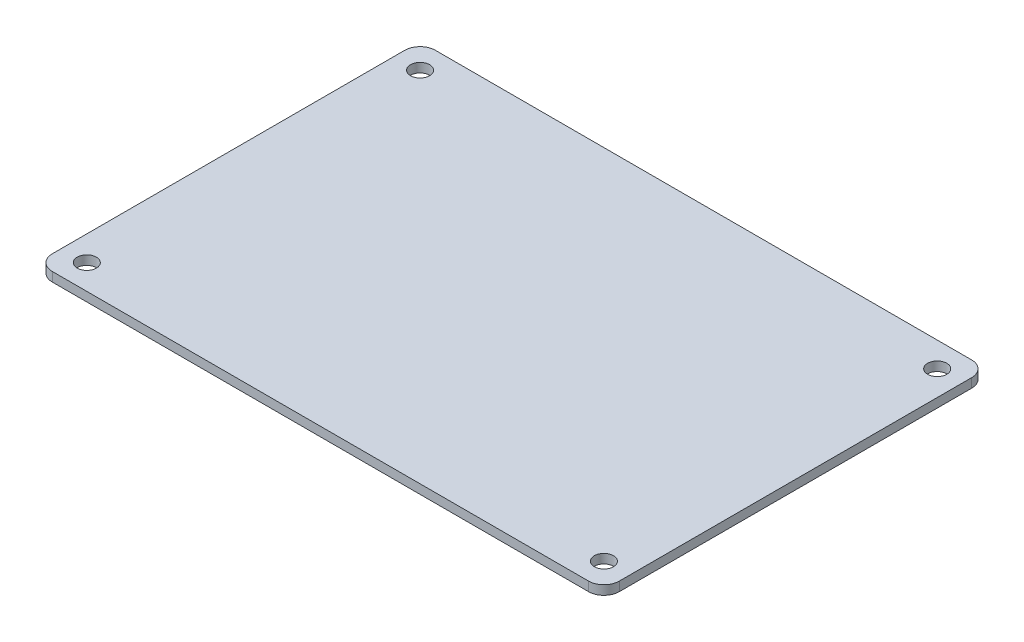
from build123d import *

# Parameters (mm, degrees)
BOSS_EXTRUDE1_DEPTH = 1.524
SKETCH2_R           = 1.5875
CUT_EXTRUDE1_DEPTH  = 2.524


with BuildPart() as part:
    # Sketch1 → Boss-Extrude1 (new body)
    with BuildSketch(Plane(origin=(0, 0, 0), x_dir=(1, 0, 0), z_dir=(0, 1, 0))):
        with BuildLine():
            Line((2.54, 0), (91.44, 0))
            ThreePointArc((91.44, 0), (93.236051224, -0.743948776), (93.98, -2.54))
            Line((93.98, -2.54), (93.98, -60.96))
            ThreePointArc((93.98, -60.96), (93.236051224, -62.756051224), (91.44, -63.5))
            Line((91.44, -63.5), (2.54, -63.5))
            ThreePointArc((2.54, -63.5), (0.743948776, -62.756051224), (0, -60.96))
            Line((0, -60.96), (0, -2.54))
            ThreePointArc((0, -2.54), (0.743948776, -0.743948776), (2.54, 0))
        make_face()
    extrude(amount=BOSS_EXTRUDE1_DEPTH)

    # Sketch2 → Cut-Extrude1 (cut, through all)
    with BuildSketch(Plane(origin=(0, 1.524, 0), x_dir=(1, 0, 0), z_dir=(0, 1, 0))):
        with Locations((4.1275, -4.1275)):
            Circle(SKETCH2_R)
        with Locations((89.8525, -4.1275)):
            Circle(SKETCH2_R)
        with Locations((4.1275, -59.3725)):
            Circle(SKETCH2_R)
        with Locations((89.8525, -59.3725)):
            Circle(SKETCH2_R)
    extrude(amount=-CUT_EXTRUDE1_DEPTH, mode=Mode.SUBTRACT)


solid = part.part
